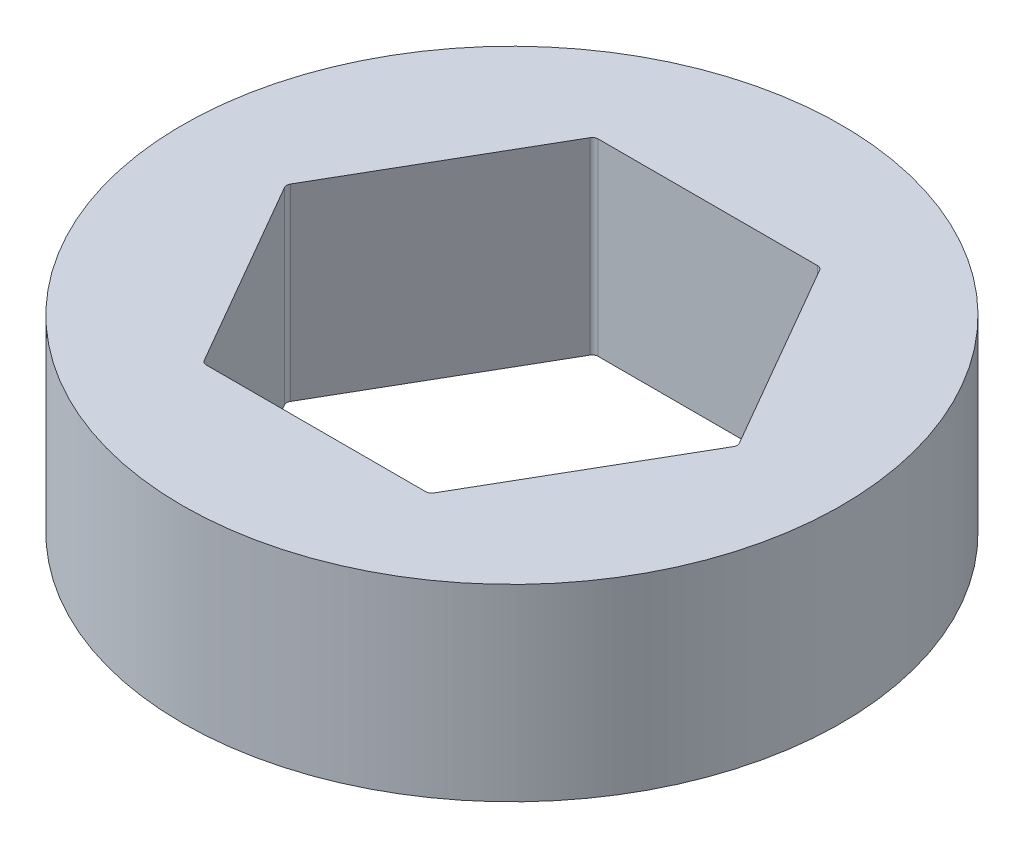
from build123d import *

# Parameters (mm, degrees)
SKETCH1_R           = 11.1125
BOSS_EXTRUDE1_DEPTH = 6.35
FILLET1_R           = 0.2


with BuildPart() as part:
    # Sketch1 → Boss-Extrude1 (new body)
    with BuildSketch(Plane(origin=(0, 0, 0), x_dir=(1, 0, 0), z_dir=(0, 1, 0))):
        Circle(SKETCH1_R)
        Polygon((7.625642355, 0), (3.812821178, 6.604), (-3.812821178, 6.604), (-7.625642355, 0), (-3.812821178, -6.604), (3.812821178, -6.604), align=None, mode=Mode.SUBTRACT)
    extrude(amount=BOSS_EXTRUDE1_DEPTH)

    # Fillet1
    fillet1_edges = [part.edges().sort_by_distance(p)[0] for p in [
        (7.625642355, 3.175, 0),
        (3.812821178, 3.175, -6.604),
        (-3.812821178, 3.175, -6.604),
        (-7.625642355, 3.175, 0),
        (-3.812821178, 3.175, 6.604),
        (3.812821178, 3.175, 6.604),
    ]]
    fillet(fillet1_edges, radius=FILLET1_R)


solid = part.part
